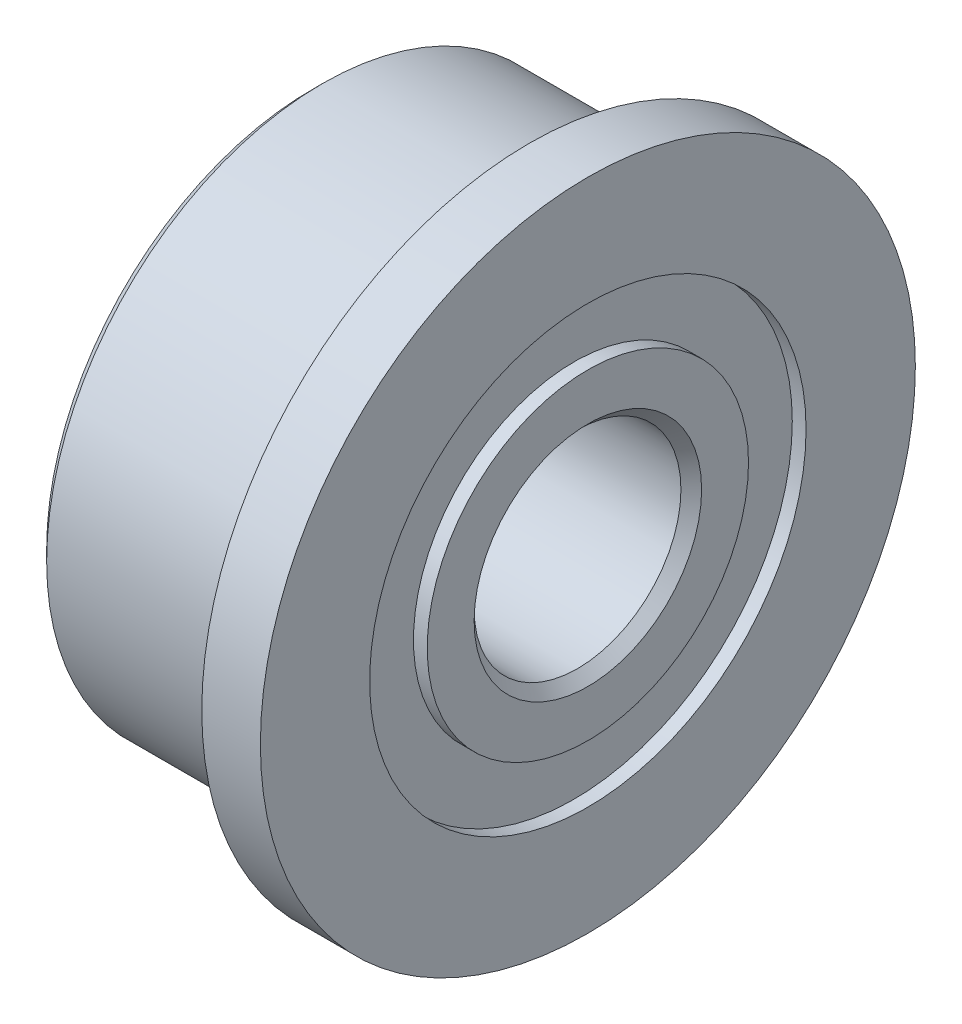
from build123d import *

# Parameters (mm, degrees)
CHAMFER1_SIZE = 0.15


with BuildPart() as part:
    # Sketch1 → Revolve1 (revolve)
    with BuildSketch(Plane.XY):
        with BuildLine():
            Line((-4, 1.5), (0, 1.5))
            Line((0, 1.5), (0, 2.33))
            Line((0, 2.33), (-0.2, 2.33))
            Line((-0.2, 2.33), (-0.2, 3.165))
            Line((-0.2, 3.165), (0, 3.165))
            Line((0, 3.165), (0, 4.75))
            Line((0, 4.75), (-0.85, 4.75))
            Line((-0.85, 4.75), (-0.85, 4.02))
            ThreePointArc((-0.85, 4.02), (-0.835857864, 3.985857864), (-0.87, 4))
            Line((-0.87, 4), (-4, 4))
            Line((-4, 4), (-4, 3.165))
            Line((-4, 3.165), (-3.8, 3.165))
            Line((-3.8, 3.165), (-3.8, 2.33))
            Line((-3.8, 2.33), (-4, 2.33))
            Line((-4, 2.33), (-4, 1.5))
        make_face()
    revolve(axis=Axis((0, 0, 0), (-1, 0, 0)))

    # Chamfer1
    chamfer1_edges = [part.edges().sort_by_distance(p)[0] for p in [
        (-4, -4, 0),
        (0, -1.5, 0),
        (-4, -1.5, 0),
    ]]
    chamfer(chamfer1_edges, length=CHAMFER1_SIZE)


solid = part.part
